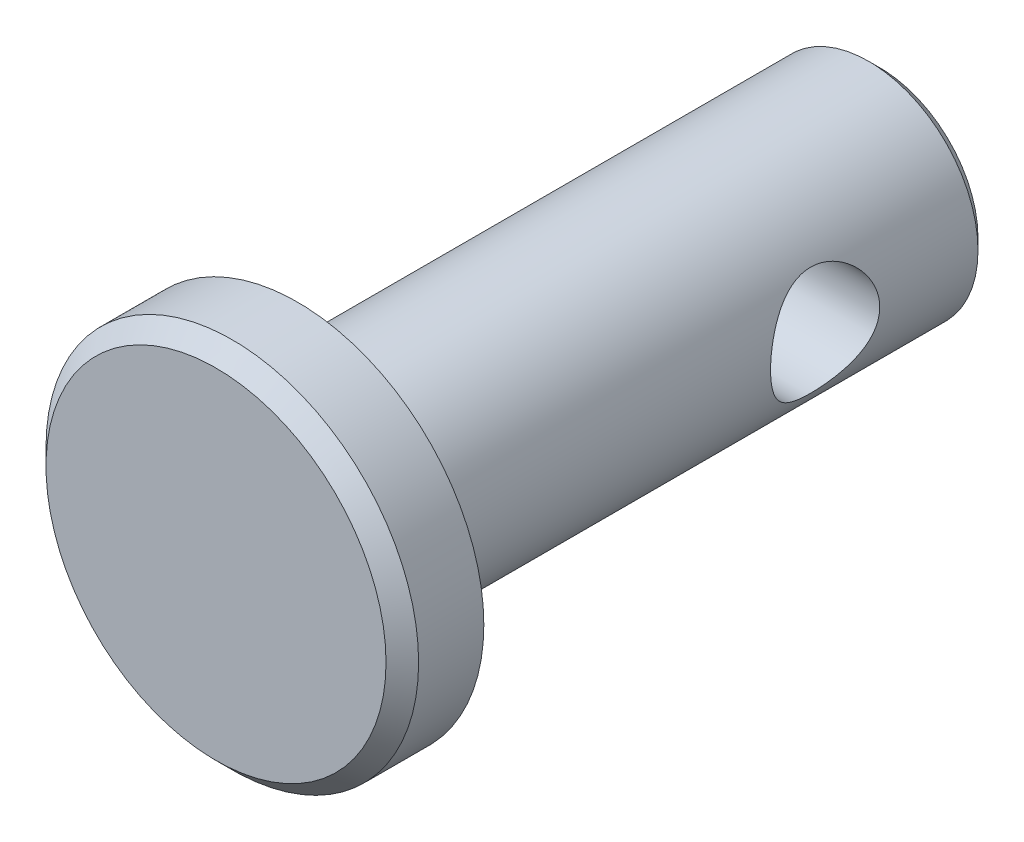
from build123d import *

# Parameters (mm, degrees)
SKETCH1_R           = 2.38125
EXTRUDE1_DEPTH      = 6.35
SKETCH2_R           = 4.064
EXTRUDE2_DEPTH      = 1.778
CHAMFER1_SIZE       = 0.3556
SKETCH3_R           = 1.190625
EXTRUDE3_DEPTH      = 5.064
EXTRUDE3_DEPTH_BACK = 5.064
CHAMFER2_SIZE       = 0.238125


with BuildPart() as part:
    # Sketch1 → Extrude1 (new body, symmetric)
    with BuildSketch(Plane.XY):
        Circle(SKETCH1_R)
    extrude(amount=EXTRUDE1_DEPTH, both=True)

    # Sketch2 → Extrude2 (add)
    with BuildSketch(Plane.XY.offset(6.35)):
        Circle(SKETCH2_R)
    extrude(amount=EXTRUDE2_DEPTH)

    # Chamfer1
    chamfer1_edges = [part.edges().sort_by_distance(p)[0] for p in [
        (-4.064, 0, 8.128),
    ]]
    chamfer(chamfer1_edges, length=CHAMFER1_SIZE)

    # Sketch3 → Extrude3 (cut, two sides)
    with BuildSketch(Plane(origin=(0, 0, 0), x_dir=(0, 0, -1), z_dir=(1, 0, 0))) as extrude3_sk:
        with Locations((2.778125, 0)):
            Circle(SKETCH3_R)
    extrude(amount=EXTRUDE3_DEPTH, mode=Mode.SUBTRACT)
    extrude(extrude3_sk.sketch, amount=-EXTRUDE3_DEPTH_BACK, mode=Mode.SUBTRACT)

    # Chamfer2
    chamfer2_edges = [part.edges().sort_by_distance(p)[0] for p in [
        (-2.38125, 0, -6.35),
    ]]
    chamfer(chamfer2_edges, length=CHAMFER2_SIZE)


solid = part.part
